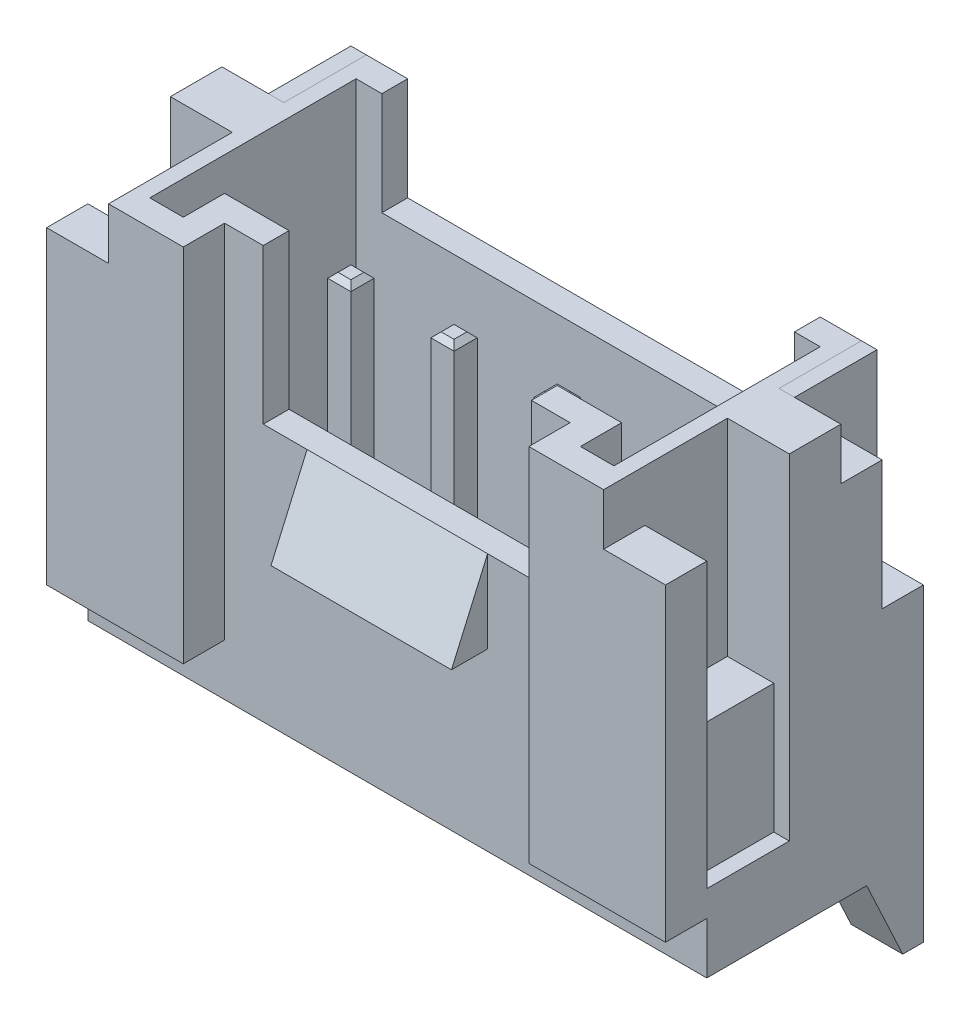
from build123d import *

# Parameters (mm, degrees)
BOSS_EXTRU_1_DEPTH                       = 6
BOSS_EXTRU_2_START                       = 5
BOSS_EXTRU_2_DEPTH                       = 1
ESQUISSE3_W                              = 6.7
ESQUISSE3_H                              = 1.6
ENL_V_MAT_EXTRU_1_DEPTH                  = 10.5
ENL_V_MAT_EXTRU_2_DEPTH                  = 6.5
ENL_V_MAT_EXTRU_4_DEPTH                  = 1.2
ESQUISSE8_W                              = 1.6
ESQUISSE8_H                              = 2.5
ENL_V_MAT_EXTRU_5_DEPTH                  = 0.3
ESQUISSE9_W                              = 5.6
ESQUISSE9_H                              = 2
ENL_V_MAT_EXTRU_6_DEPTH                  = 1.5
ENL_V_MAT_EXTRU_7_REACH                  = 6.2
ESQUISSE10_W                             = 5.2
ESQUISSE10_H                             = 6
BOSS_EXTRU_3_DEPTH                       = 1.75
ESQUISSE5_W                              = 8
ESQUISSE5_H                              = 1
ENL_V_MAT_EXTRU_3_DEPTH                  = 2
EXTRU_MINCE1_START                       = 3
EXTRU_MINCE1_DEPTH                       = 0.225
CHANFREIN1_SIZE                          = 0.1
CHANFREIN2_SIZE                          = 0.6
CHANFREIN2_SIZE2                         = 0.3
R_P_TITION_LIN_AIRE1_COUNT               = 4
R_P_TITION_LIN_AIRE1_PITCH               = 2
CHANFREIN1_OF_R_P_TITION_LIN_AIRE1_SIZE  = 0.1
CHANFREIN2_OF_R_P_TITION_LIN_AIRE1_SIZE2 = 0.6
CHANFREIN2_OF_R_P_TITION_LIN_AIRE1_SIZE  = 0.3
BOSS_EXTRU_4_DEPTH                       = 0.3
BOSS_EXTRU_5_DEPTH                       = 0.3


with BuildPart() as part:
    # Esquisse1 → Boss.-Extru.1 (new body, symmetric)
    with BuildSketch(Plane(origin=(0, 0, 0), x_dir=(0, 0, -1), z_dir=(1, 0, 0))):
        Polygon((0, 0), (-5, 0), (-5, -7), (-4.2, -7), (-4.2, -8), (0, -8), align=None)
    extrude(amount=BOSS_EXTRU_1_DEPTH, both=True)

    # Esquisse2 → Boss.-Extru.2 (add)
    with BuildSketch(Plane(origin=(0, 0, 0), x_dir=(0, 0, -1), z_dir=(1, 0, 0)).offset(BOSS_EXTRU_2_START)):
        Polygon((0, -8), (0, -9.5), (-0.4, -9.5), (-1.099461487, -8), align=None)
    boss_extru_2 = extrude(amount=BOSS_EXTRU_2_DEPTH)

    # Esquisse3 → Enlèv. mat.-Extru.1 (cut, through all)
    with BuildSketch(Plane(origin=(0, 0, 0), x_dir=(1, 0, 0), z_dir=(0, 1, 0))):
        with Locations((0, -5)):
            Rectangle(ESQUISSE3_W, ESQUISSE3_H)
    extrude(amount=-ENL_V_MAT_EXTRU_1_DEPTH, mode=Mode.SUBTRACT)

    # Esquisse4 → Enlèv. mat.-Extru.2 (cut)
    with BuildSketch(Plane(origin=(0, 0, 0), x_dir=(1, 0, 0), z_dir=(0, 1, 0))):
        Polygon((-4.5, -4.5), (-3.85, -4.5), (-3.85, -3.7), (3.85, -3.7), (3.85, -4.5), (4.5, -4.5), (4.5, -0.5), (-4.5, -0.5), align=None)
    extrude(amount=-ENL_V_MAT_EXTRU_2_DEPTH, mode=Mode.SUBTRACT)

    # Esquisse7 → Enlèv. mat.-Extru.4 (cut)
    with BuildSketch(Plane(origin=(6, 0, 0), x_dir=(0, 0, -1), z_dir=(1, 0, 0))):
        Polygon((-5, -1), (-4.2, -1), (-4.2, -4), (-2.6, -4), (-2.6, 0), (-5, 0), align=None)
        Polygon((0, 0), (-1.6, 0), (-1.6, -1), (-0.8, -1), (-0.8, -3.5), (0, -3.5), align=None)
    enl_v_mat_extru_4 = extrude(amount=-ENL_V_MAT_EXTRU_4_DEPTH, mode=Mode.SUBTRACT)

    # Esquisse8 → Enlèv. mat.-Extru.5 (cut)
    with BuildSketch(Plane(origin=(6, 0, 0), x_dir=(0, 0, -1), z_dir=(1, 0, 0))):
        with Locations((-3.4, -5.25)):
            Rectangle(ESQUISSE8_W, ESQUISSE8_H)
    enl_v_mat_extru_5 = extrude(amount=-ENL_V_MAT_EXTRU_5_DEPTH, mode=Mode.SUBTRACT)

    # Esquisse9 → Enlèv. mat.-Extru.6 (cut, through all)
    with BuildSketch(Plane.XY.offset(0.5)):
        Rectangle(ESQUISSE9_W, ESQUISSE9_H)
    extrude(amount=-ENL_V_MAT_EXTRU_6_DEPTH, mode=Mode.SUBTRACT)

    # Esquisse10 → Enlèv. mat.-Extru.7 (cut, up to next)
    with BuildSketch(Plane.XY.offset(4.2), mode=Mode.PRIVATE) as enl_v_mat_extru_7_sk1:
        Rectangle(ESQUISSE10_W, ESQUISSE10_H)
    enl_v_mat_extru_7_tool1 = extrude(enl_v_mat_extru_7_sk1.sketch, amount=-ENL_V_MAT_EXTRU_7_REACH, mode=Mode.PRIVATE) & part.part
    add(enl_v_mat_extru_7_tool1.solids().sort_by_distance((0, 0, 4.2))[0], mode=Mode.SUBTRACT)

    # Esquisse12 → Boss.-Extru.3 (add, symmetric)
    with BuildSketch(Plane(origin=(0, 0, 0), x_dir=(0, 0, -1), z_dir=(1, 0, 0))):
        Polygon((-4.2, -3), (-4.9, -4.6), (-4.2, -4.6), align=None)
    extrude(amount=BOSS_EXTRU_3_DEPTH, both=True)

    # Esquisse5 → Enlèv. mat.-Extru.3 (cut)
    with BuildSketch(Plane(origin=(0, 0, 0), x_dir=(1, 0, 0), z_dir=(0, 1, 0))):
        Rectangle(ESQUISSE5_W, ESQUISSE5_H)
    extrude(amount=-ENL_V_MAT_EXTRU_3_DEPTH, mode=Mode.SUBTRACT)


with BuildPart() as body_2:
    # Esquisse13 → Extru.-Mince1 (new body, symmetric)
    with BuildSketch(Plane(origin=(0, 0, 0), x_dir=(0, 0, -1), z_dir=(1, 0, 0)).offset(EXTRU_MINCE1_START)):
        with BuildLine():
            Line((-2.325, -1.7), (-2.325, -8))
            ThreePointArc((-2.325, -8), (-2.185875721, -8.335875721), (-1.85, -8.475))
            Line((-1.85, -8.475), (-0.5, -8.475))
            ThreePointArc((-0.5, -8.475), (-0.48232233, -8.48232233), (-0.475, -8.5))
            Line((-0.475, -8.5), (-0.475, -10))
            Line((-0.475, -10), (-0.025, -10))
            Line((-0.025, -10), (-0.025, -8.5))
            ThreePointArc((-0.025, -8.5), (-0.164124279, -8.164124279), (-0.5, -8.025))
            Line((-0.5, -8.025), (-1.85, -8.025))
            ThreePointArc((-1.85, -8.025), (-1.86767767, -8.01767767), (-1.875, -8))
            Line((-1.875, -8), (-1.875, -1.7))
            Line((-1.875, -1.7), (-2.325, -1.7))
        make_face()
    extru_mince1 = extrude(amount=EXTRU_MINCE1_DEPTH, both=True)

    # Chanfrein1
    chanfrein1_edges = [body_2.edges().sort_by_distance(p)[0] for p in [
        (2.775, -1.7, 2.1),
        (3, -1.7, 2.325),
        (3, -1.7, 1.875),
        (3.225, -1.7, 2.1),
    ]]
    chamfer(chanfrein1_edges, length=CHANFREIN1_SIZE)

    # Chanfrein2
    chanfrein2_edges = [body_2.edges().sort_by_distance(p)[0] for p in [
        (3, -10, 0.475),
    ]]
    chanfrein2_side = [body_2.faces().sort_by_distance(p)[0] for p in [
        (3, -9.25, 0.475),
    ]]
    chamfer(chanfrein2_edges, length=CHANFREIN2_SIZE, length2=CHANFREIN2_SIZE2, reference=chanfrein2_side[0])


with BuildPart() as part_1:
    add(part.part)

    # Répétition linéaire1: Extru.-Mince1 ×4
    with Locations(*[(-i * R_P_TITION_LIN_AIRE1_PITCH, 0, 0) for i in range(1, R_P_TITION_LIN_AIRE1_COUNT)]):
        add(extru_mince1)

    # Chanfrein1 of Répétition linéaire1
    chanfrein1_of_r_p_tition_lin_aire1_edges = [part_1.edges().sort_by_distance(p)[0] for p in [
        (0.775, -1.7, 2.1),
        (1, -1.7, 2.325),
        (1, -1.7, 1.875),
        (1.225, -1.7, 2.1),
        (-1.225, -1.7, 2.1),
        (-1, -1.7, 2.325),
        (-1, -1.7, 1.875),
        (-0.775, -1.7, 2.1),
        (-3.225, -1.7, 2.1),
        (-3, -1.7, 2.325),
        (-3, -1.7, 1.875),
        (-2.775, -1.7, 2.1),
    ]]
    chamfer(chanfrein1_of_r_p_tition_lin_aire1_edges, length=CHANFREIN1_OF_R_P_TITION_LIN_AIRE1_SIZE)

    # Chanfrein2 of Répétition linéaire1
    chanfrein2_of_r_p_tition_lin_aire1_edges = [part_1.edges().sort_by_distance(p)[0] for p in [
        (1, -10, 0.475),
        (-1, -10, 0.475),
        (-3, -10, 0.475),
    ]]
    chamfer(chanfrein2_of_r_p_tition_lin_aire1_edges, length=CHANFREIN2_OF_R_P_TITION_LIN_AIRE1_SIZE, length2=CHANFREIN2_OF_R_P_TITION_LIN_AIRE1_SIZE2)

    # Symétrie2: Boss.-Extru.2, Enlèv. mat.-Extru.4, Enlèv. mat.-Extru.5 across plane
    add(boss_extru_2.mirror(Plane(origin=(0, 0, 0), x_dir=(0, 0, 1), z_dir=(1, 0, 0))))
    add(enl_v_mat_extru_4.mirror(Plane(origin=(0, 0, 0), x_dir=(0, 0, 1), z_dir=(1, 0, 0))), mode=Mode.SUBTRACT)
    add(enl_v_mat_extru_5.mirror(Plane(origin=(0, 0, 0), x_dir=(0, 0, 1), z_dir=(1, 0, 0))), mode=Mode.SUBTRACT)


with BuildPart() as body_3:
    # Esquisse14 → Boss.-Extru.4 (new body)
    with BuildSketch(Plane(origin=(4.8, 0, 0), x_dir=(0, 0, -1), z_dir=(1, 0, 0))):
        Polygon((0, -3.5), (0, 0), (-1.6, 0), (-1.6, -1), (-0.8, -1), (-0.8, -3.5), align=None)
    extrude(amount=BOSS_EXTRU_4_DEPTH)


with BuildPart() as body_4:
    # Esquisse15 → Boss.-Extru.5 (new body)
    with BuildSketch(Plane.ZY.offset(4.8)):
        Polygon((0, 0), (0, -3.5), (0.8, -3.5), (0.8, -1), (1.6, -1), (1.6, 0), align=None)
    extrude(amount=BOSS_EXTRU_5_DEPTH)


solid = Compound([body_2.part, part_1.part, body_3.part, body_4.part])
